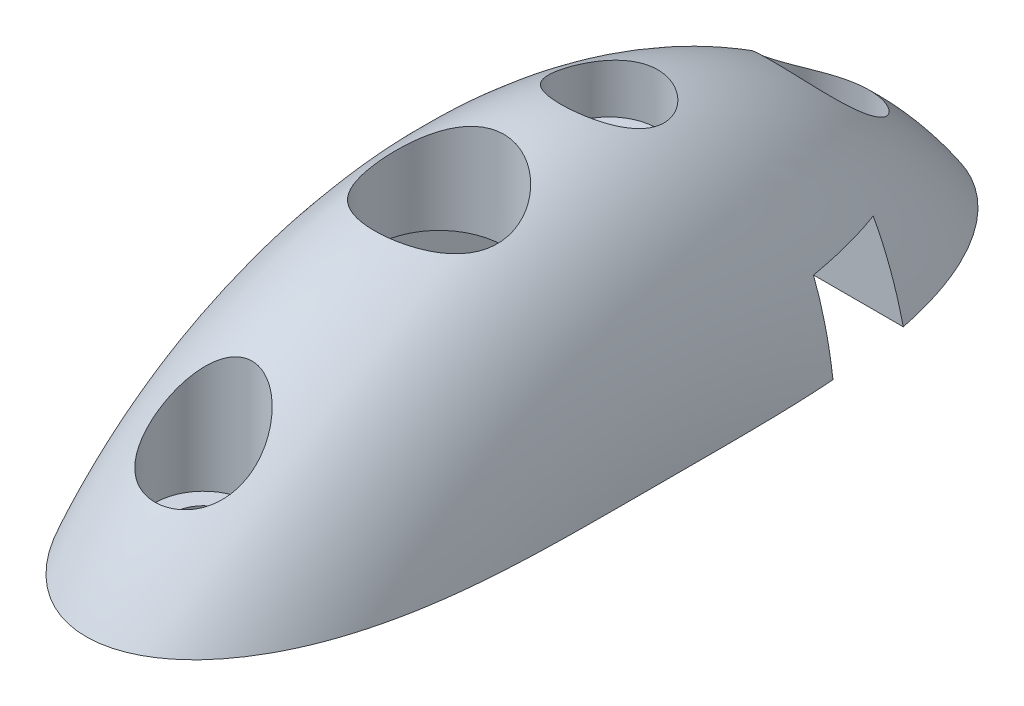
from build123d import *

# Parameters (mm, degrees)
CUT_EXTRUDE1_REACH             = 33.75
SKETCH2_W                      = 19.05
SKETCH2_H                      = 64.439050054
CUT_EXTRUDE1_DIRECTION_2_DEPTH = 32.7500001
SKETCH3_W                      = 12
SKETCH3_H                      = 21
CUT_EXTRUDE2_DEPTH             = 8
SKETCH4_R                      = 4
CUT_EXTRUDE3_DEPTH             = 6.9700001
SKETCH7_W                      = 19.05
SKETCH7_H                      = 5
CUT_EXTRUDE4_DEPTH             = 5


with BuildPart() as part:
    # Sketch1 → Revolve1 (revolve)
    with BuildSketch(Plane.XY):
        with BuildLine():
            Line((-9.525, 0), (-9.525, -17.78))
            Line((-9.525, -17.78), (9.525, -17.78))
            Line((9.525, -17.78), (9.525, 0))
            add(Edge.make_bspline(
                [(9.525, 0), (9.525, 13.97), (0, 13.97), (-9.525, 13.97), (-9.525, 0)],
                knots=[1.570796327, 1.570796327, 1.570796327, 3.141592654, 3.141592654, 4.71238898, 4.71238898, 4.71238898], degree=2, weights=[1, 0.707106781, 1, 0.707106781, 1]))
        make_face()
    revolve(axis=Axis((-20.584458519, -17.78, 0), (1, 0, 0)))

    # Sketch2 → Cut-Extrude1 (cut, up to next)
    with BuildSketch(Plane.XY, mode=Mode.PRIVATE) as cut_extrude1_sk1:
        with Locations((0, -32.219525027)):
            Rectangle(SKETCH2_W, SKETCH2_H)
    cut_extrude1_tool1 = extrude(cut_extrude1_sk1.sketch, amount=-CUT_EXTRUDE1_REACH, mode=Mode.PRIVATE) & part.part
    add(cut_extrude1_tool1.solids().sort_by_distance((0, -32.219525, 0))[0], mode=Mode.SUBTRACT)

    # Sketch2 → Cut-Extrude1 direction 2 (cut)
    with BuildSketch(Plane.XY):
        with Locations((0, -32.219525027)):
            Rectangle(SKETCH2_W, SKETCH2_H)
    extrude(amount=CUT_EXTRUDE1_DIRECTION_2_DEPTH, mode=Mode.SUBTRACT)

    # Sketch3 → Cut-Extrude2 (cut)
    with BuildSketch(Plane.XZ):
        Rectangle(SKETCH3_W, SKETCH3_H)
    extrude(amount=-CUT_EXTRUDE2_DEPTH, mode=Mode.SUBTRACT)

    # Sketch4 → Cut-Extrude3 (cut, through all)
    with BuildSketch(Plane.XZ.offset(-8)):
        with Locations((0, 4.5)):
            Circle(SKETCH4_R)
    extrude(amount=-CUT_EXTRUDE3_DEPTH, mode=Mode.SUBTRACT)

    # Sketch5 → Cut-Revolve1 (revolve, cut)
    with BuildSketch(Plane(origin=(0, 0, 0), x_dir=(0, 0, -1), z_dir=(1, 0, 0))):
        Polygon((-16.05, 13.97), (-16.05, 2.032), (-17.145, 2.032), (-17.145, 0), (-19.05, 0), (-19.05, 13.97), align=None)
    cut_revolve1 = revolve(axis=Axis((0, 0, 19.05), (0, -1, 0)), mode=Mode.SUBTRACT)

    # Mirror1: Cut-Revolve1 across plane
    add(cut_revolve1.mirror(Plane.XY), mode=Mode.SUBTRACT)

    # Sketch6 → Cut-Revolve2 (revolve, cut)
    with BuildSketch(Plane(origin=(0, 0, 0), x_dir=(0, 0, -1), z_dir=(1, 0, 0))):
        Polygon((3, 13.97), (3, 9.524), (4.095, 9.524), (4.095, 0), (6, 0), (6, 13.97), align=None)
    revolve(axis=Axis((0, 0, -6), (0, -1, 0)), mode=Mode.SUBTRACT)

    # Sketch7 → Cut-Extrude4 (cut)
    with BuildSketch(Plane.XZ):
        with Locations((0, -13)):
            Rectangle(SKETCH7_W, SKETCH7_H)
    extrude(amount=-CUT_EXTRUDE4_DEPTH, mode=Mode.SUBTRACT)


solid = part.part
